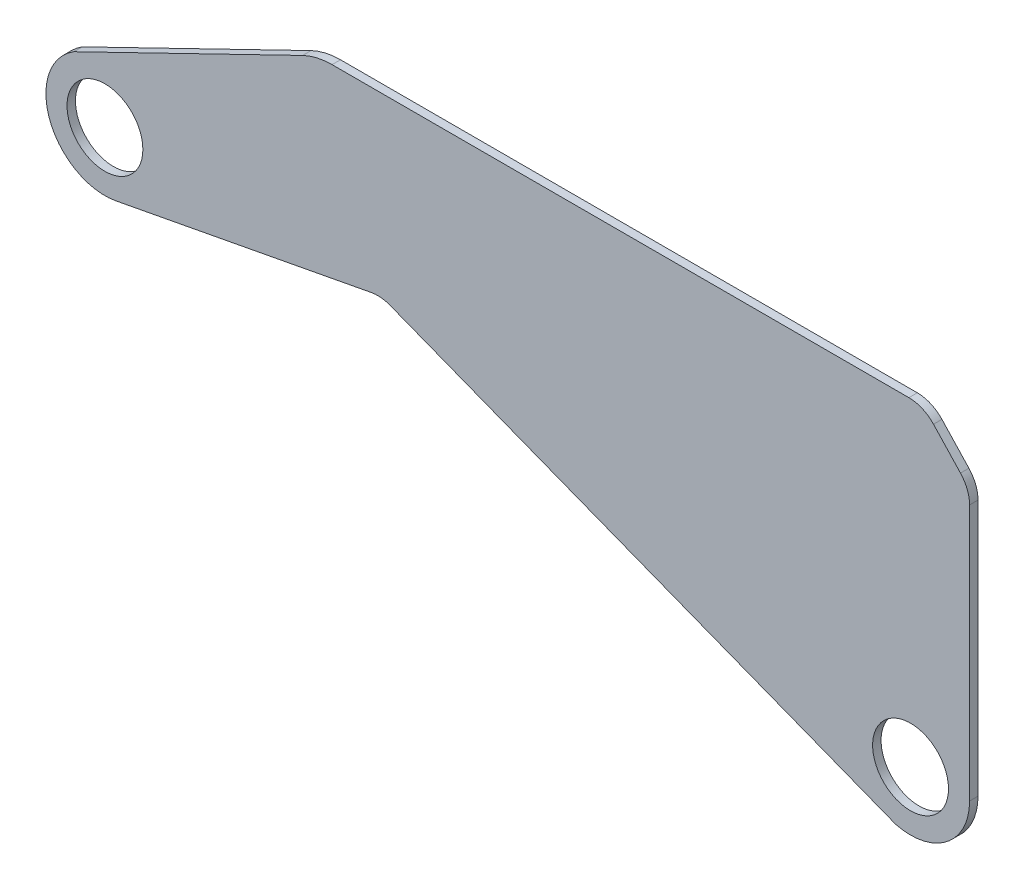
from build123d import *

# Parameters (mm, degrees)
SKETCH1_R           = 14.2875
BOSS_EXTRUDE1_DEPTH = 3.175
FILLET1_R           = 12.7
FILLET2_R           = 25.4
FILLET3_R           = 12.7
FILLET4_R           = 12.7


with BuildPart() as part:
    # Sketch1 → Boss-Extrude1 (new body)
    with BuildSketch(Plane.XY):
        with BuildLine():
            ThreePointArc((-5.519049503, -21.528834562), (13.625155959, -17.558637479), (22.225, 0))
            Line((22.225, 0), (22.225, 101.6))
            Line((22.225, 101.6), (4.879081578, 120.154759877))
            Line((4.879081578, 120.154759877), (-223.720918422, 120.154759877))
            Line((-223.720918422, 120.154759877), (-311.078676661, 77.714630478))
            Line((-311.078676661, 77.714630478), (-315.107157175, 75.757514845))
            ThreePointArc((-315.107157175, 75.757514845), (-324.150818676, 48.808615563), (-299.298978098, 35.009448714))
            Line((-299.298978098, 35.009448714), (-199.469861892, 53.896151905))
            Line((-199.469861892, 53.896151905), (-5.519049503, -21.528834562))
        make_face()
        Circle(SKETCH1_R, mode=Mode.SUBTRACT)
        with Locations((-303.430444421, 56.847067884)):
            Circle(SKETCH1_R, mode=Mode.SUBTRACT)
    extrude(amount=BOSS_EXTRUDE1_DEPTH)

    # Fillet1
    fillet1_edges = [part.edges().sort_by_distance(p)[0] for p in [
        (-199.469861892, 53.896151905, 1.5875),
    ]]
    fillet(fillet1_edges, radius=FILLET1_R)

    # Fillet2
    fillet2_edges = [part.edges().sort_by_distance(p)[0] for p in [
        (-223.720918422, 120.154759877, 1.5875),
    ]]
    fillet(fillet2_edges, radius=FILLET2_R)

    # Fillet3
    fillet3_edges = [part.edges().sort_by_distance(p)[0] for p in [
        (22.225, 101.6, 1.5875),
    ]]
    fillet(fillet3_edges, radius=FILLET3_R)

    # Fillet4
    fillet4_edges = [part.edges().sort_by_distance(p)[0] for p in [
        (4.879081578, 120.154759877, 1.5875),
    ]]
    fillet(fillet4_edges, radius=FILLET4_R)


solid = part.part
